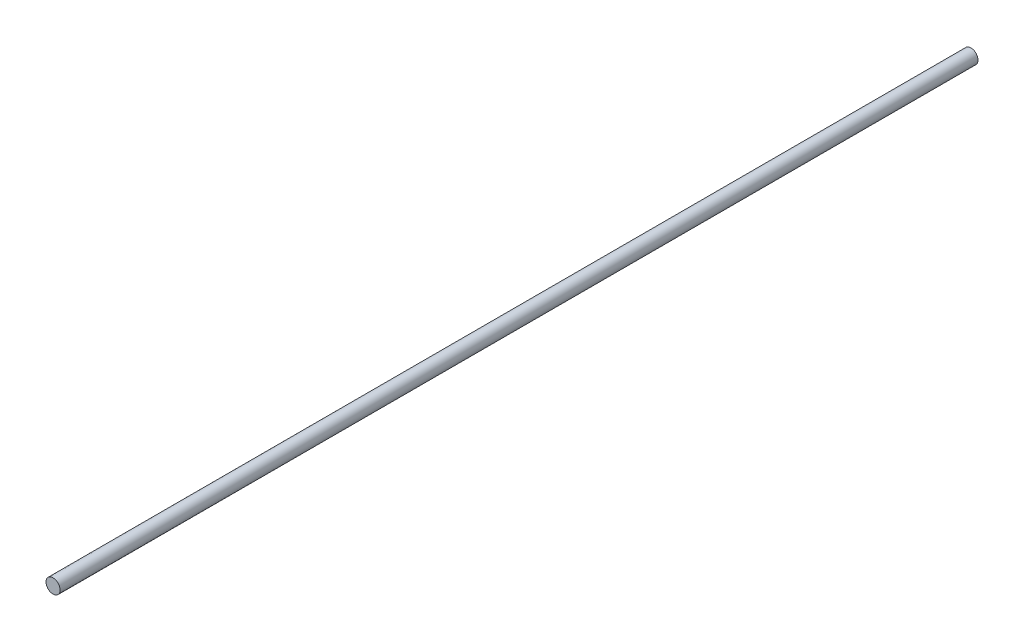
from build123d import *

# Parameters (mm, degrees)
SKETCH1_R                = 1.1
BOSS_EXTRUDE2_DEPTH      = 130
BOSS_EXTRUDE2_DEPTH_BACK = 13


with BuildPart() as part:
    # Sketch1 → Boss-Extrude2 (new body, two sides)
    with BuildSketch(Plane.XY) as boss_extrude2_sk:
        with Locations((-0.726888422, 0.561376025)):
            Circle(SKETCH1_R)
    extrude(amount=BOSS_EXTRUDE2_DEPTH)
    extrude(boss_extrude2_sk.sketch, amount=-BOSS_EXTRUDE2_DEPTH_BACK)


solid = part.part
